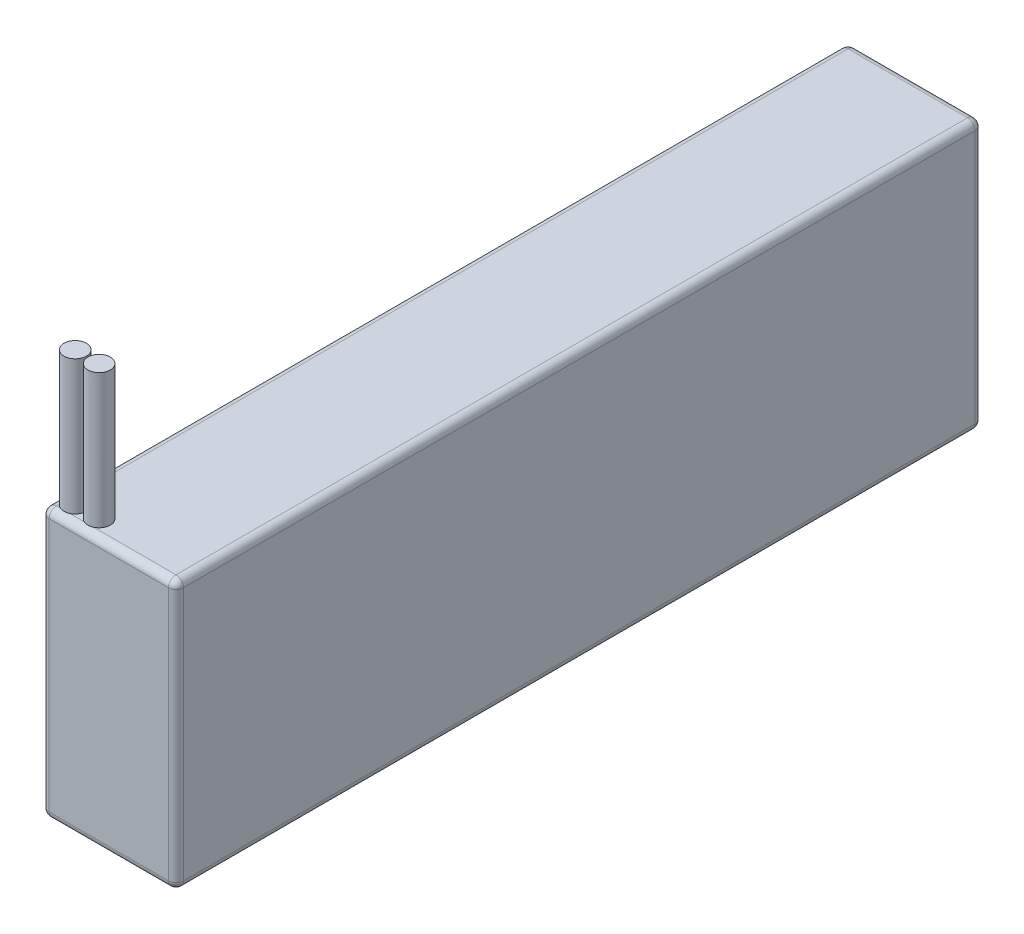
from build123d import *

# Parameters (mm, degrees)
SKETCH1_W           = 137.16
SKETCH1_H           = 45.72
BOSS_EXTRUDE1_DEPTH = 22.86
FILLET1_R           = 1.27
SKETCH2_R           = 1.905
BOSS_EXTRUDE2_DEPTH = 22.86


with BuildPart() as part:
    # Sketch1 → Boss-Extrude1 (new body)
    with BuildSketch(Plane(origin=(0, 0, 0), x_dir=(0, 0, -1), z_dir=(1, 0, 0))):
        Rectangle(SKETCH1_W, SKETCH1_H)
    extrude(amount=BOSS_EXTRUDE1_DEPTH)

    # Fillet1
    fillet1_edges = [part.edges().sort_by_distance(p)[0] for p in [
        (22.86, 0, 68.58),
        (22.86, -22.86, 0),
        (22.86, 0, -68.58),
        (0, -22.86, 0),
        (0, 0, 68.58),
        (0, 22.86, 0),
        (0, 0, -68.58),
        (22.86, 22.86, 0),
        (11.43, -22.86, -68.58),
        (11.43, -22.86, 68.58),
        (11.43, 22.86, 68.58),
        (11.43, 22.86, -68.58),
    ]]
    fillet(fillet1_edges, radius=FILLET1_R)

    # Sketch2 → Boss-Extrude2 (add)
    with BuildSketch(Plane(origin=(0, 22.86, 0), x_dir=(1, 0, 0), z_dir=(0, 1, 0))):
        with Locations((2.722644531, -65.585417965)):
            Circle(SKETCH2_R)
        with Locations((6.786644531, -65.585417965)):
            Circle(SKETCH2_R)
    extrude(amount=BOSS_EXTRUDE2_DEPTH)


solid = part.part
